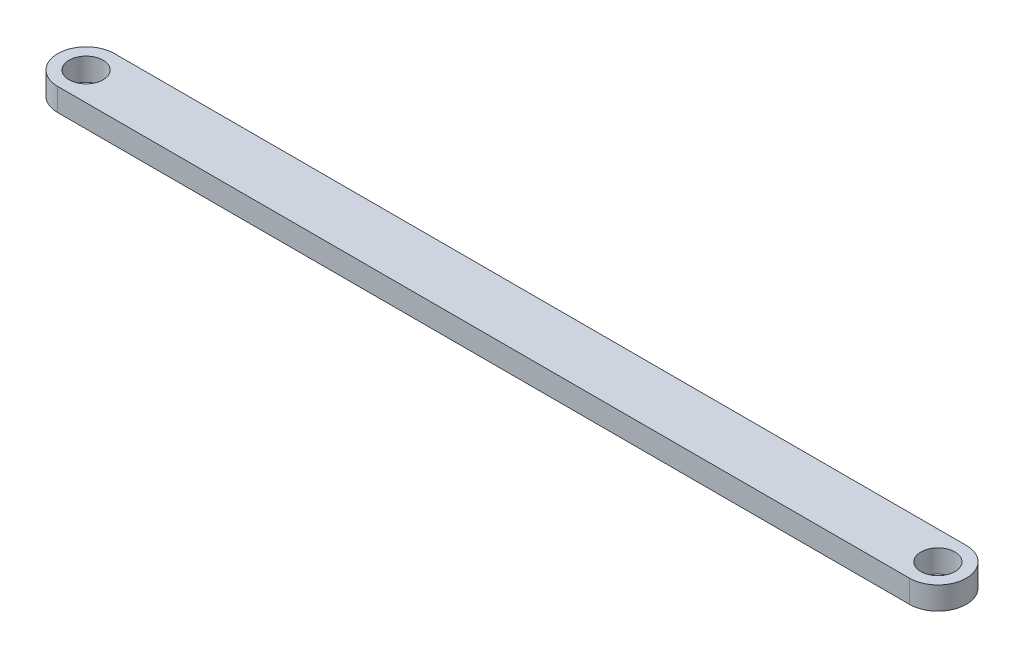
from build123d import *

# Parameters (mm, degrees)
SKETCH1_R           = 3
BOSS_EXTRUDE1_DEPTH = 4


with BuildPart() as part:
    # Sketch1 → Boss-Extrude1 (new body)
    with BuildSketch(Plane(origin=(0, 0, 0), x_dir=(1, 0, 0), z_dir=(0, 1, 0))):
        with BuildLine():
            Line((150, 5), (0, 5))
            ThreePointArc((0, 5), (-5, 0), (0, -5))
            Line((0, -5), (150, -5))
            ThreePointArc((150, -5), (155, 0), (150, 5))
        make_face()
        Circle(SKETCH1_R, mode=Mode.SUBTRACT)
        with Locations((150, 0)):
            Circle(SKETCH1_R, mode=Mode.SUBTRACT)
    extrude(amount=BOSS_EXTRUDE1_DEPTH)


solid = part.part
